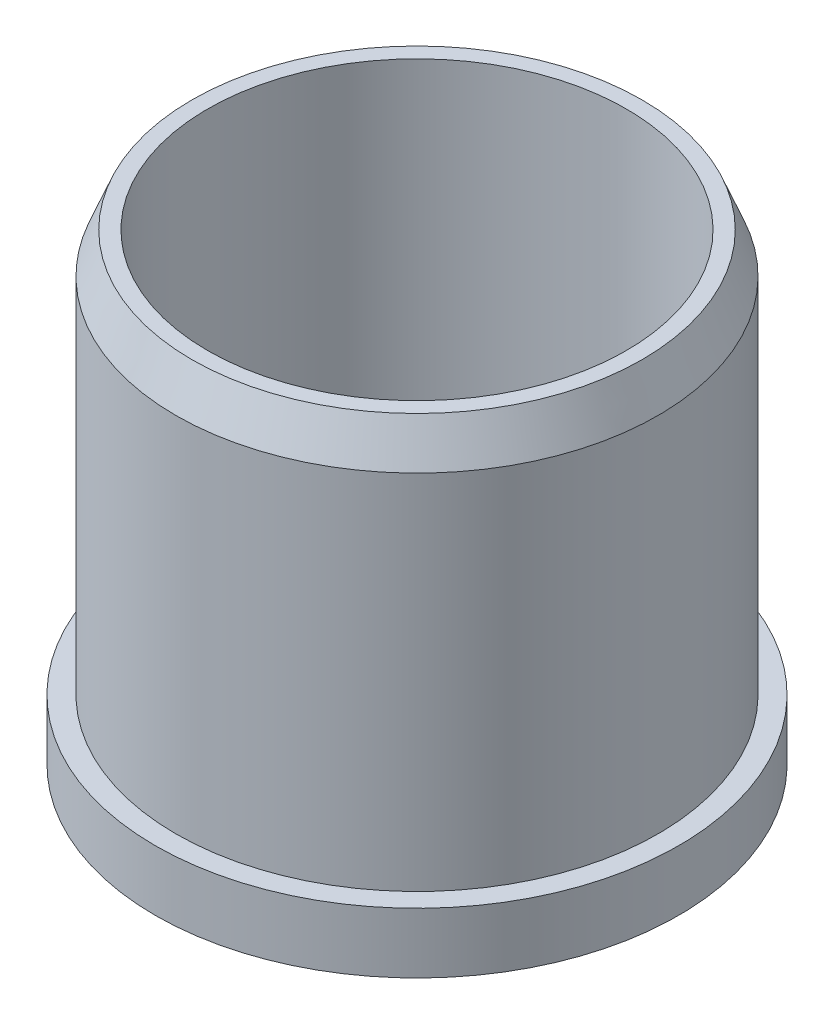
from build123d import *

# Parameters (mm, degrees)
SKETCH1_R           = 41.275
SKETCH1_R_2         = 6.5024
SKETCH1_R_3         = 7.62
BOSS_EXTRUDE1_DEPTH = 9.525
SKETCH2_R           = 38.0365
SKETCH2_R_2         = 33.02
BOSS_EXTRUDE2_DEPTH = 63.5
SKETCH3_R           = 12.7
SKETCH3_R_2         = 6.5024
BOSS_EXTRUDE3_DEPTH = 15.875
CHAMFER1_SIZE       = 6.35
CHAMFER1_SIZE2      = 2.54
SKETCH4_R           = 12.7
SKETCH4_R_2         = 6.5024
BOSS_EXTRUDE4_DEPTH = 6.35
FILLET1_R           = 2.54


with BuildPart() as part:
    # Sketch1 → Boss-Extrude1 (new body)
    with BuildSketch(Plane(origin=(0, 0, 0), x_dir=(1, 0, 0), z_dir=(0, 1, 0))):
        Circle(SKETCH1_R)
        Circle(SKETCH1_R_2, mode=Mode.SUBTRACT)
        with Locations((0, 22.86)):
            Circle(SKETCH1_R_3, mode=Mode.SUBTRACT)
        with Locations((21.741151963, 7.064128491)):
            Circle(SKETCH1_R_3, mode=Mode.SUBTRACT)
        with Locations((13.436770867, -18.494128491)):
            Circle(SKETCH1_R_3, mode=Mode.SUBTRACT)
        with Locations((-13.436770867, -18.494128491)):
            Circle(SKETCH1_R_3, mode=Mode.SUBTRACT)
        with Locations((-21.741151963, 7.064128491)):
            Circle(SKETCH1_R_3, mode=Mode.SUBTRACT)
    extrude(amount=BOSS_EXTRUDE1_DEPTH)

    # Sketch2 → Boss-Extrude2 (add)
    with BuildSketch(Plane(origin=(0, 9.525, 0), x_dir=(1, 0, 0), z_dir=(0, 1, 0))):
        Circle(SKETCH2_R)
        Circle(SKETCH2_R_2, mode=Mode.SUBTRACT)
    extrude(amount=BOSS_EXTRUDE2_DEPTH)

    # Sketch3 → Boss-Extrude3 (add)
    with BuildSketch(Plane(origin=(0, 9.525, 0), x_dir=(1, 0, 0), z_dir=(0, 1, 0))):
        Circle(SKETCH3_R)
        Circle(SKETCH3_R_2, mode=Mode.SUBTRACT)
    extrude(amount=BOSS_EXTRUDE3_DEPTH)

    # Chamfer1
    chamfer1_edges = [part.edges().sort_by_distance(p)[0] for p in [
        (-38.0365, 73.025, 0),
    ]]
    chamfer1_side = [part.faces().sort_by_distance(p)[0] for p in [
        (-38.0365, 41.275, 0),
    ]]
    chamfer(chamfer1_edges, length=CHAMFER1_SIZE, length2=CHAMFER1_SIZE2, reference=chamfer1_side[0])

    # Sketch4 → Boss-Extrude4 (add)
    with BuildSketch(Plane(origin=(0, 25.4, 0), x_dir=(1, 0, 0), z_dir=(0, 1, 0))):
        Circle(SKETCH4_R)
        Circle(SKETCH4_R_2, mode=Mode.SUBTRACT)
    extrude(amount=BOSS_EXTRUDE4_DEPTH)

    # Fillet1
    fillet1_edges = [part.edges().sort_by_distance(p)[0] for p in [
        (-12.7, 31.75, 0),
    ]]
    fillet(fillet1_edges, radius=FILLET1_R)


solid = part.part
